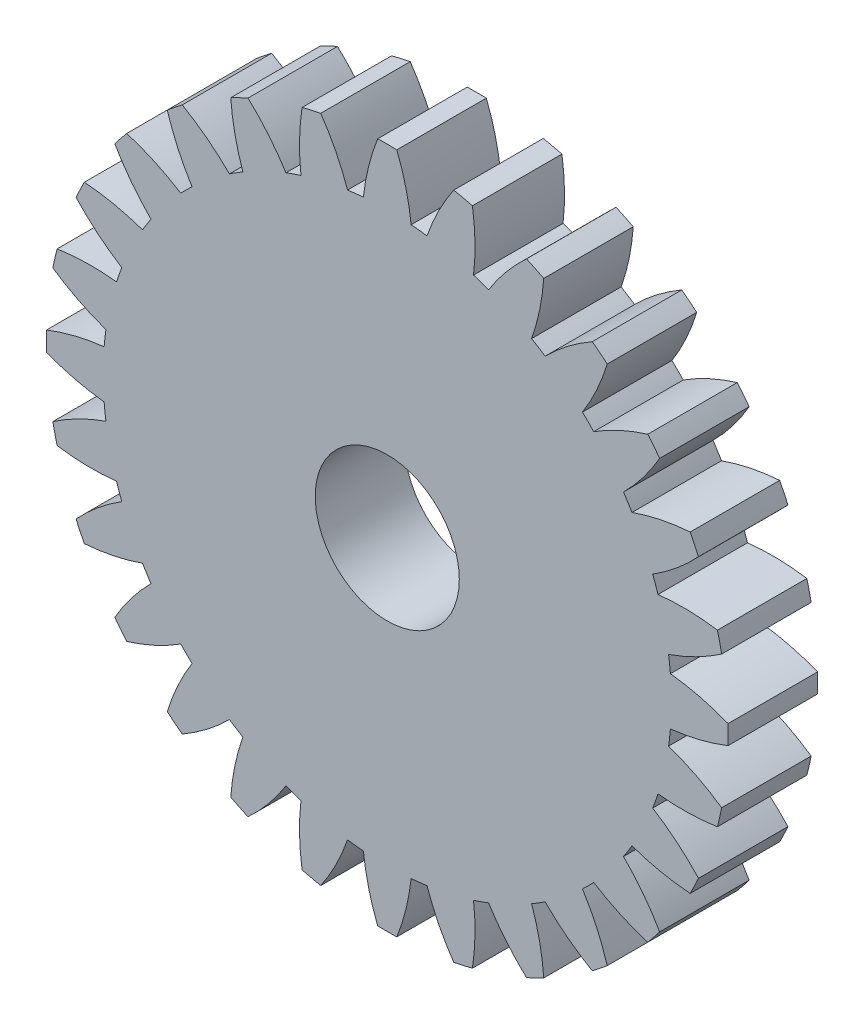
from build123d import *

# Parameters (mm, degrees)
SKETCH1_R           = 4.025
BOSS_EXTRUDE1_DEPTH = 5


with BuildPart() as part:
    # Sketch1 → Boss-Extrude1 (new body)
    with BuildSketch(Plane.XY.offset(5)):
        with BuildLine():
            ThreePointArc((-4.820868329, 15.125305073), (-5.243180109, 14.984147869), (-5.661366831, 14.831201927))
            ThreePointArc((-5.661366831, 14.831201927), (-6.63581244, 16.180559962), (-7.780863095, 17.388521199))
            ThreePointArc((-7.780863095, 17.388521199), (-8.26548523, 17.163456934), (-8.743604518, 16.924889365))
            ThreePointArc((-8.743604518, 16.924889365), (-8.513109799, 15.276501202), (-8.065696106, 13.673337973))
            ThreePointArc((-8.065696106, 13.673337973), (-8.446009215, 13.441746663), (-8.819677449, 13.199580095))
            ThreePointArc((-8.819677449, 13.199580095), (-10.069952083, 14.29827236), (-11.455090589, 15.221149746))
            ThreePointArc((-11.455090589, 15.221149746), (-11.877480725, 14.893889741), (-12.290526286, 14.554912009))
            ThreePointArc((-12.290526286, 14.554912009), (-11.699009678, 12.999142279), (-10.906076201, 11.535732612))
            ThreePointArc((-10.906076201, 11.535732612), (-11.225320151, 11.225320151), (-11.535732612, 10.906076201))
            ThreePointArc((-11.535732612, 10.906076201), (-12.999142279, 11.699009678), (-14.554912009, 12.290526286))
            ThreePointArc((-14.554912009, 12.290526286), (-14.893889741, 11.877480725), (-15.221149746, 11.455090589))
            ThreePointArc((-15.221149746, 11.455090589), (-14.29827236, 10.069952083), (-13.199580095, 8.819677449))
            ThreePointArc((-13.199580095, 8.819677449), (-13.441746663, 8.446009215), (-13.673337973, 8.065696106))
            ThreePointArc((-13.673337973, 8.065696106), (-15.276501202, 8.513109799), (-16.924889365, 8.743604518))
            ThreePointArc((-16.924889365, 8.743604518), (-17.163456934, 8.26548523), (-17.388521199, 7.780863095))
            ThreePointArc((-17.388521199, 7.780863095), (-16.180559962, 6.63581244), (-14.831201927, 5.661366831))
            ThreePointArc((-14.831201927, 5.661366831), (-14.984147869, 5.243180109), (-15.125305073, 4.820868329))
            ThreePointArc((-15.125305073, 4.820868329), (-16.787832566, 4.900327047), (-18.446182096, 4.758241909))
            ThreePointArc((-18.446182096, 4.758241909), (-18.572376727, 4.239023792), (-18.683959592, 3.716470634))
            ThreePointArc((-18.683959592, 3.716470634), (-17.251486724, 2.868925453), (-15.719125365, 2.21917164))
            ThreePointArc((-15.719125365, 2.21917164), (-15.775181332, 1.777436058), (-15.818826219, 1.334302083))
            ThreePointArc((-15.818826219, 1.334302083), (-17.457351905, 1.041821436), (-19.042506233, 0.534281182))
            ThreePointArc((-19.042506233, 0.534281182), (-19.05, 0), (-19.042506233, -0.534281182))
            ThreePointArc((-19.042506233, -0.534281182), (-17.457351905, -1.041821436), (-15.818826219, -1.334302083))
            ThreePointArc((-15.818826219, -1.334302083), (-15.775181332, -1.777436058), (-15.719125365, -2.21917164))
            ThreePointArc((-15.719125365, -2.21917164), (-17.251486724, -2.868925453), (-18.683959592, -3.716470634))
            ThreePointArc((-18.683959592, -3.716470634), (-18.572376727, -4.239023792), (-18.446182096, -4.758241909))
            ThreePointArc((-18.446182096, -4.758241909), (-16.787832566, -4.900327047), (-15.125305073, -4.820868329))
            ThreePointArc((-15.125305073, -4.820868329), (-14.984147869, -5.243180109), (-14.831201927, -5.661366831))
            ThreePointArc((-14.831201927, -5.661366831), (-16.180559962, -6.63581244), (-17.388521199, -7.780863095))
            ThreePointArc((-17.388521199, -7.780863095), (-17.163456934, -8.26548523), (-16.924889365, -8.743604518))
            ThreePointArc((-16.924889365, -8.743604518), (-15.276501202, -8.513109799), (-13.673337973, -8.065696106))
            ThreePointArc((-13.673337973, -8.065696106), (-13.441746663, -8.446009215), (-13.199580095, -8.819677449))
            ThreePointArc((-13.199580095, -8.819677449), (-14.29827236, -10.069952083), (-15.221149746, -11.455090589))
            ThreePointArc((-15.221149746, -11.455090589), (-14.893889741, -11.877480725), (-14.554912009, -12.290526286))
            ThreePointArc((-14.554912009, -12.290526286), (-12.999142279, -11.699009678), (-11.535732612, -10.906076201))
            ThreePointArc((-11.535732612, -10.906076201), (-11.225320151, -11.225320151), (-10.906076201, -11.535732612))
            ThreePointArc((-10.906076201, -11.535732612), (-11.699009678, -12.999142279), (-12.290526286, -14.554912009))
            ThreePointArc((-12.290526286, -14.554912009), (-11.877480725, -14.893889741), (-11.455090589, -15.221149746))
            ThreePointArc((-11.455090589, -15.221149746), (-10.069952083, -14.29827236), (-8.819677449, -13.199580095))
            ThreePointArc((-8.819677449, -13.199580095), (-8.446009215, -13.441746663), (-8.065696106, -13.673337973))
            ThreePointArc((-8.065696106, -13.673337973), (-8.513109799, -15.276501202), (-8.743604518, -16.924889365))
            ThreePointArc((-8.743604518, -16.924889365), (-8.26548523, -17.163456934), (-7.780863095, -17.388521199))
            ThreePointArc((-7.780863095, -17.388521199), (-6.63581244, -16.180559962), (-5.661366831, -14.831201927))
            ThreePointArc((-5.661366831, -14.831201927), (-5.243180109, -14.984147869), (-4.820868329, -15.125305073))
            ThreePointArc((-4.820868329, -15.125305073), (-4.900327047, -16.787832566), (-4.758241909, -18.446182096))
            ThreePointArc((-4.758241909, -18.446182096), (-4.239023792, -18.572376727), (-3.716470634, -18.683959592))
            ThreePointArc((-3.716470634, -18.683959592), (-2.868925453, -17.251486724), (-2.21917164, -15.719125365))
            ThreePointArc((-2.21917164, -15.719125365), (-1.777436058, -15.775181332), (-1.334302083, -15.818826219))
            ThreePointArc((-1.334302083, -15.818826219), (-1.041821436, -17.457351905), (-0.534281182, -19.042506233))
            ThreePointArc((-0.534281182, -19.042506233), (0, -19.05), (0.534281182, -19.042506233))
            ThreePointArc((0.534281182, -19.042506233), (1.041821436, -17.457351905), (1.334302083, -15.818826219))
            ThreePointArc((1.334302083, -15.818826219), (1.777436058, -15.775181332), (2.21917164, -15.719125365))
            ThreePointArc((2.21917164, -15.719125365), (2.868925453, -17.251486724), (3.716470634, -18.683959592))
            ThreePointArc((3.716470634, -18.683959592), (4.239023792, -18.572376727), (4.758241909, -18.446182096))
            ThreePointArc((4.758241909, -18.446182096), (4.900327047, -16.787832566), (4.820868329, -15.125305073))
            ThreePointArc((4.820868329, -15.125305073), (5.243180109, -14.984147869), (5.661366831, -14.831201927))
            ThreePointArc((5.661366831, -14.831201927), (6.63581244, -16.180559962), (7.780863095, -17.388521199))
            ThreePointArc((7.780863095, -17.388521199), (8.26548523, -17.163456934), (8.743604518, -16.924889365))
            ThreePointArc((8.743604518, -16.924889365), (8.513109799, -15.276501202), (8.065696106, -13.673337973))
            ThreePointArc((8.065696106, -13.673337973), (8.446009215, -13.441746663), (8.819677449, -13.199580095))
            ThreePointArc((8.819677449, -13.199580095), (10.069952083, -14.29827236), (11.455090589, -15.221149746))
            ThreePointArc((11.455090589, -15.221149746), (11.877480725, -14.893889741), (12.290526286, -14.554912009))
            ThreePointArc((12.290526286, -14.554912009), (11.699009678, -12.999142279), (10.906076201, -11.535732612))
            ThreePointArc((10.906076201, -11.535732612), (11.225320151, -11.225320151), (11.535732612, -10.906076201))
            ThreePointArc((11.535732612, -10.906076201), (12.999142279, -11.699009678), (14.554912009, -12.290526286))
            ThreePointArc((14.554912009, -12.290526286), (14.893889741, -11.877480725), (15.221149746, -11.455090589))
            ThreePointArc((15.221149746, -11.455090589), (14.29827236, -10.069952083), (13.199580095, -8.819677449))
            ThreePointArc((13.199580095, -8.819677449), (13.441746663, -8.446009215), (13.673337973, -8.065696106))
            ThreePointArc((13.673337973, -8.065696106), (15.276501202, -8.513109799), (16.924889365, -8.743604518))
            ThreePointArc((16.924889365, -8.743604518), (17.163456934, -8.26548523), (17.388521199, -7.780863095))
            ThreePointArc((17.388521199, -7.780863095), (16.180559962, -6.63581244), (14.831201927, -5.661366831))
            ThreePointArc((14.831201927, -5.661366831), (14.984147869, -5.243180109), (15.125305073, -4.820868329))
            ThreePointArc((15.125305073, -4.820868329), (16.787832566, -4.900327047), (18.446182096, -4.758241909))
            ThreePointArc((18.446182096, -4.758241909), (18.572376727, -4.239023792), (18.683959592, -3.716470634))
            ThreePointArc((18.683959592, -3.716470634), (17.251486724, -2.868925453), (15.719125365, -2.21917164))
            ThreePointArc((15.719125365, -2.21917164), (15.775181332, -1.777436058), (15.818826219, -1.334302083))
            ThreePointArc((15.818826219, -1.334302083), (17.457351905, -1.041821436), (19.042506233, -0.534281182))
            ThreePointArc((19.042506233, -0.534281182), (19.05, 0), (19.042506233, 0.534281182))
            ThreePointArc((19.042506233, 0.534281182), (17.457351905, 1.041821436), (15.818826219, 1.334302083))
            ThreePointArc((15.818826219, 1.334302083), (15.775181332, 1.777436058), (15.719125365, 2.21917164))
            ThreePointArc((15.719125365, 2.21917164), (17.251486724, 2.868925453), (18.683959592, 3.716470634))
            ThreePointArc((18.683959592, 3.716470634), (18.572376727, 4.239023792), (18.446182096, 4.758241909))
            ThreePointArc((18.446182096, 4.758241909), (16.787832566, 4.900327047), (15.125305073, 4.820868329))
            ThreePointArc((15.125305073, 4.820868329), (14.984147869, 5.243180109), (14.831201927, 5.661366831))
            ThreePointArc((14.831201927, 5.661366831), (16.180559962, 6.63581244), (17.388521199, 7.780863095))
            ThreePointArc((17.388521199, 7.780863095), (17.163456934, 8.26548523), (16.924889365, 8.743604518))
            ThreePointArc((16.924889365, 8.743604518), (15.276501202, 8.513109799), (13.673337973, 8.065696106))
            ThreePointArc((13.673337973, 8.065696106), (13.441746663, 8.446009215), (13.199580095, 8.819677449))
            ThreePointArc((13.199580095, 8.819677449), (14.29827236, 10.069952083), (15.221149746, 11.455090589))
            ThreePointArc((15.221149746, 11.455090589), (14.893889741, 11.877480725), (14.554912009, 12.290526286))
            ThreePointArc((14.554912009, 12.290526286), (12.999142279, 11.699009678), (11.535732612, 10.906076201))
            ThreePointArc((11.535732612, 10.906076201), (11.225320151, 11.225320151), (10.906076201, 11.535732612))
            ThreePointArc((10.906076201, 11.535732612), (11.699009678, 12.999142279), (12.290526286, 14.554912009))
            ThreePointArc((12.290526286, 14.554912009), (11.877480725, 14.893889741), (11.455090589, 15.221149746))
            ThreePointArc((11.455090589, 15.221149746), (10.069952083, 14.29827236), (8.819677449, 13.199580095))
            ThreePointArc((8.819677449, 13.199580095), (8.446009215, 13.441746663), (8.065696106, 13.673337973))
            ThreePointArc((8.065696106, 13.673337973), (8.513109799, 15.276501202), (8.743604518, 16.924889365))
            ThreePointArc((8.743604518, 16.924889365), (8.26548523, 17.163456934), (7.780863095, 17.388521199))
            ThreePointArc((7.780863095, 17.388521199), (6.63581244, 16.180559962), (5.661366831, 14.831201927))
            ThreePointArc((5.661366831, 14.831201927), (5.243180109, 14.984147869), (4.820868329, 15.125305073))
            ThreePointArc((4.820868329, 15.125305073), (4.900327047, 16.787832566), (4.758241909, 18.446182096))
            ThreePointArc((4.758241909, 18.446182096), (4.239023792, 18.572376727), (3.716470634, 18.683959592))
            ThreePointArc((3.716470634, 18.683959592), (2.868925453, 17.251486724), (2.21917164, 15.719125365))
            ThreePointArc((2.21917164, 15.719125365), (1.777436058, 15.775181332), (1.334302083, 15.818826219))
            ThreePointArc((1.334302083, 15.818826219), (1.041821436, 17.457351905), (0.534281182, 19.042506233))
            ThreePointArc((0.534281182, 19.042506233), (0, 19.05), (-0.534281182, 19.042506233))
            ThreePointArc((-0.534281182, 19.042506233), (-1.041821436, 17.457351905), (-1.334302083, 15.818826219))
            ThreePointArc((-1.334302083, 15.818826219), (-1.777436058, 15.775181332), (-2.21917164, 15.719125365))
            ThreePointArc((-2.21917164, 15.719125365), (-2.868925453, 17.251486724), (-3.716470634, 18.683959592))
            ThreePointArc((-3.716470634, 18.683959592), (-4.239023792, 18.572376727), (-4.758241909, 18.446182096))
            ThreePointArc((-4.758241909, 18.446182096), (-4.900327047, 16.787832566), (-4.820868329, 15.125305073))
        make_face()
        Circle(SKETCH1_R, mode=Mode.SUBTRACT)
    extrude(amount=-BOSS_EXTRUDE1_DEPTH)


solid = part.part
